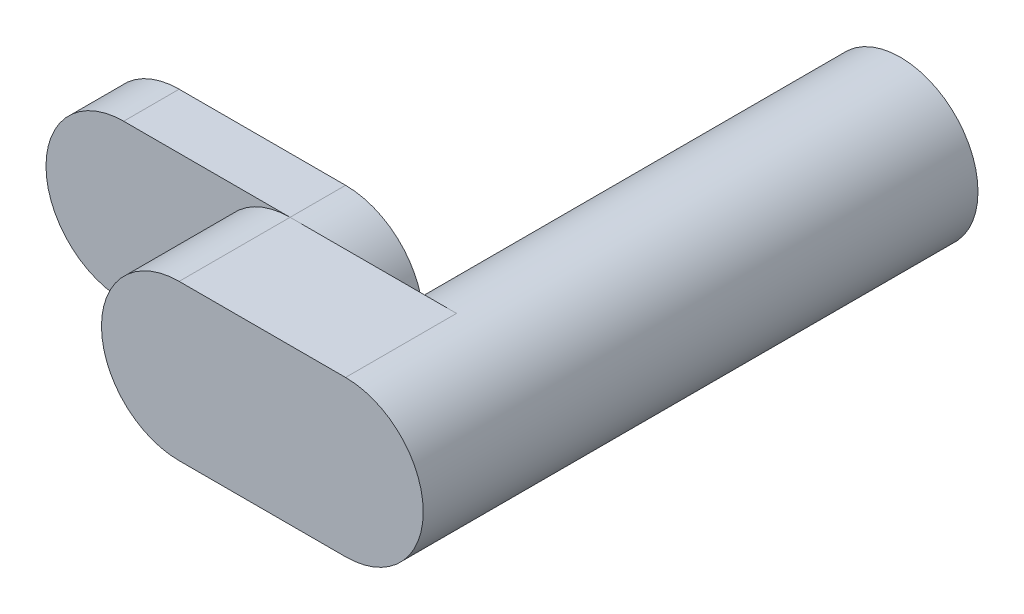
from build123d import *

# Parameters (mm, degrees)
SZKIC1_R                    = 70
DODANIE_WYCI_GNI_CIE1_DEPTH = 400
DODANIE_WYCI_GNI_CIE2_DEPTH = 100
DODANIE_WYCI_GNI_CIE3_START = 50
DODANIE_WYCI_GNI_CIE3_DEPTH = 50


with BuildPart() as part:
    # Szkic1 → Dodanie-wyciągnięcie1 (new body)
    with BuildSketch(Plane.XY):
        Circle(SZKIC1_R)
    extrude(amount=DODANIE_WYCI_GNI_CIE1_DEPTH)

    # Szkic2 → Dodanie-wyciągnięcie2 (add)
    with BuildSketch(Plane.XY.offset(400)):
        with BuildLine():
            Line((0, -70), (-150, -70))
            ThreePointArc((-150, -70), (-220, 0), (-150, 70))
            Line((-150, 70), (0, 70))
            ThreePointArc((0, 70), (70, 0), (0, -70))
        make_face()
    extrude(amount=DODANIE_WYCI_GNI_CIE2_DEPTH)

    # Szkic3 → Dodanie-wyciągnięcie3 (add)
    with BuildSketch(Plane(origin=(0, 0, 400), x_dir=(-1, 0, 0), z_dir=(0, 0, -1)).offset(DODANIE_WYCI_GNI_CIE3_START)):
        with BuildLine():
            Line((150, 70), (300, 70))
            ThreePointArc((300, 70), (370, 0), (300, -70))
            Line((300, -70), (150, -70))
            ThreePointArc((150, -70), (80, 0), (150, 70))
        make_face()
    extrude(amount=-DODANIE_WYCI_GNI_CIE3_DEPTH)


solid = part.part
